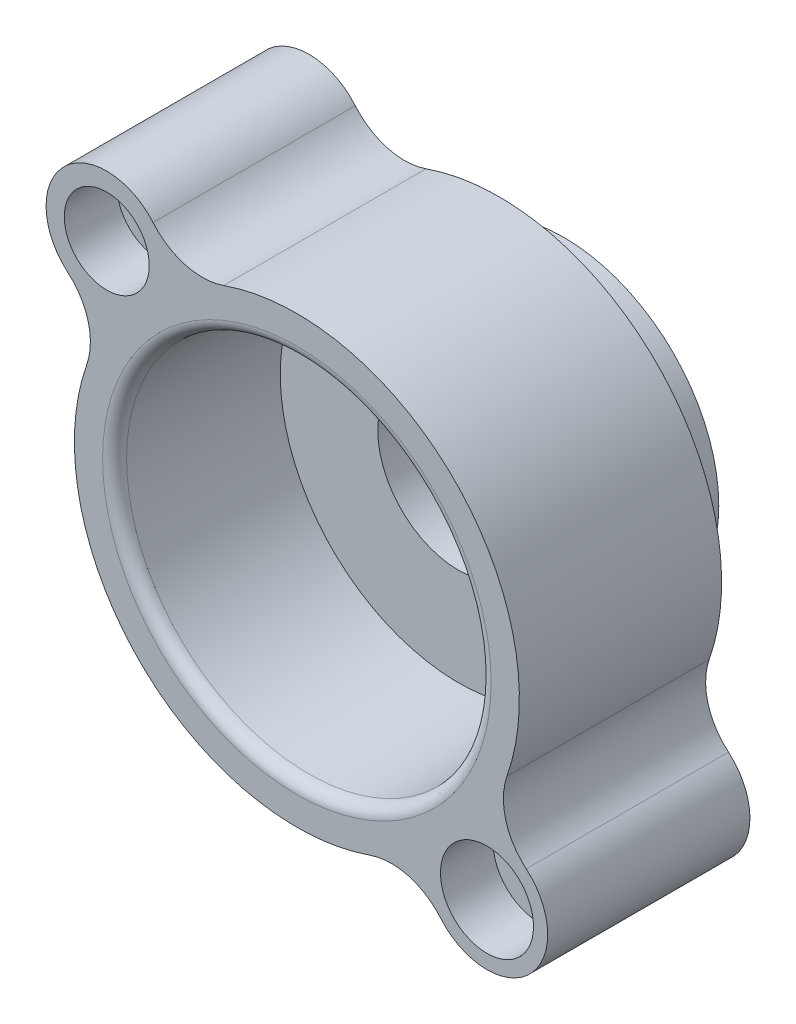
from build123d import *

# Parameters (mm, degrees)
BOSS_EXTRU_1_DEPTH      = 635
ESQUISSE2_R             = 486.41
BOSS_EXTRU_2_DEPTH      = 203.2
ESQUISSE3_R             = 572.77
ENL_V_MAT_EXTRU_1_DEPTH = 508
ENL_V_MAT_EXTRU_1_TAPER = 1.432096184
ESQUISSE4_R             = 254
ENL_V_MAT_EXTRU_2_DEPTH = 331.2
PER_AGE1_D              = 139.7
PER_AGE1_DEPTH          = 838.2
PER_AGE1_CBORE_D        = 266.7
PER_AGE1_CBORE_DEPTH    = 165.1
PER_AGE2_D              = 139.7
PER_AGE2_DEPTH          = 838.2
PER_AGE2_CBORE_D        = 292.1
PER_AGE2_CBORE_DEPTH    = 165.1
CONG_1_R                = 38.1


with BuildPart() as part:
    # Esquisse1 → Boss.-Extru.1 (new body)
    with BuildSketch(Plane.XY.offset(838.2)):
        with BuildLine():
            ThreePointArc((-720.101782381, 451.601786597), (-655.471932336, 350.063866609), (-659.625858178, 229.773752251))
            ThreePointArc((-659.625858178, 229.773752251), (-493.914086659, -493.914086659), (229.773752251, -659.625858178))
            ThreePointArc((229.773752251, -659.625858178), (350.063866609, -655.471932336), (451.601786597, -720.101782381))
            ThreePointArc((451.601786597, -720.101782381), (731.603841816, -731.603841816), (720.101782381, -451.601786597))
            ThreePointArc((720.101782381, -451.601786597), (655.471932336, -350.063866609), (659.625858178, -229.773752251))
            ThreePointArc((659.625858178, -229.773752251), (493.914086659, 493.914086659), (-229.773752251, 659.625858178))
            ThreePointArc((-229.773752251, 659.625858178), (-350.063866609, 655.471932336), (-451.601786597, 720.101782381))
            ThreePointArc((-451.601786597, 720.101782381), (-731.603841816, 731.603841816), (-720.101782381, 451.601786597))
        make_face()
    extrude(amount=-BOSS_EXTRU_1_DEPTH)

    # Esquisse2 → Boss.-Extru.2 (add)
    with BuildSketch(Plane(origin=(0, 0, 203.2), x_dir=(-1, 0, 0), z_dir=(0, 0, -1))):
        Circle(ESQUISSE2_R)
    extrude(amount=BOSS_EXTRU_2_DEPTH)

    # Esquisse3 → Enlèv. mat.-Extru.1 (cut)
    with BuildSketch(Plane.XY.offset(838.2)):
        Circle(ESQUISSE3_R)
    extrude(amount=-ENL_V_MAT_EXTRU_1_DEPTH, taper=ENL_V_MAT_EXTRU_1_TAPER, mode=Mode.SUBTRACT)

    # Esquisse4 → Enlèv. mat.-Extru.2 (cut, through all)
    with BuildSketch(Plane.XY.offset(330.2)):
        Circle(ESQUISSE4_R)
    extrude(amount=-ENL_V_MAT_EXTRU_2_DEPTH, mode=Mode.SUBTRACT)

    # Perçage1
    with Locations(Plane.XY.offset(838.2)):
        with Locations((-596.9, 596.9)):
            CounterBoreHole(PER_AGE1_D / 2, PER_AGE1_CBORE_D / 2, PER_AGE1_CBORE_DEPTH, depth=PER_AGE1_DEPTH)

    # Perçage2
    with Locations(Plane.XY.offset(838.2)):
        with Locations((596.9, -596.9)):
            CounterBoreHole(PER_AGE2_D / 2, PER_AGE2_CBORE_D / 2, PER_AGE2_CBORE_DEPTH, depth=PER_AGE2_DEPTH)

    # Congé1
    cong_1_edges = [part.edges().sort_by_distance(p)[0] for p in [
        (-572.77, 0, 838.2),
    ]]
    fillet(cong_1_edges, radius=CONG_1_R)


solid = part.part
